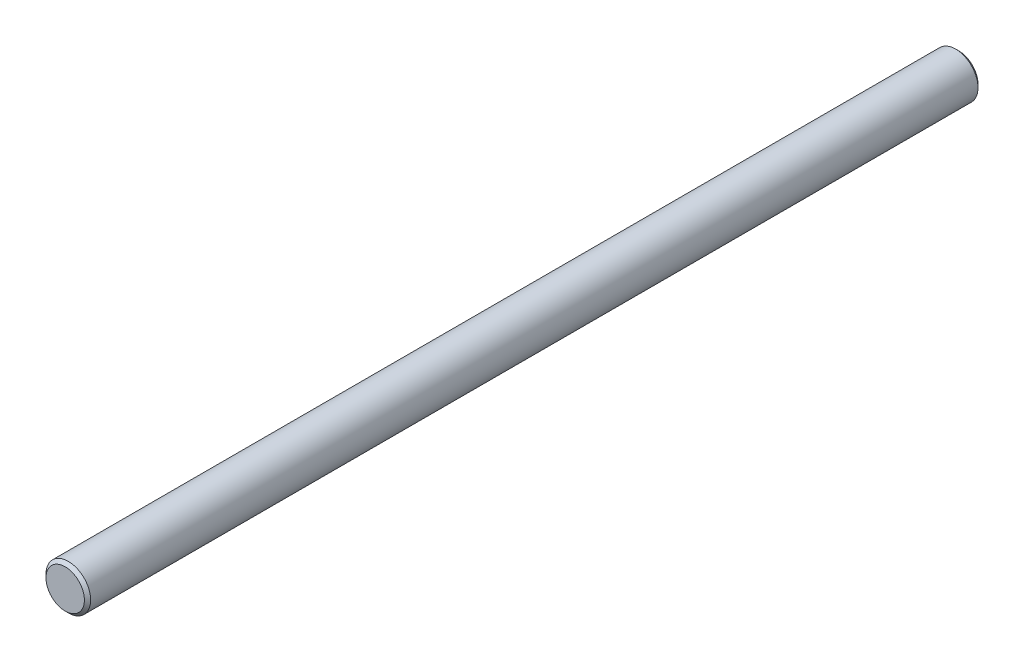
from build123d import *

# Parameters (mm, degrees)
SKETCH3_R                = 15
BOSS_EXTRUDE1_DEPTH      = 300
BOSS_EXTRUDE1_DEPTH_BACK = 300
CHAMFER1_SIZE            = 2.1


with BuildPart() as part:
    # Sketch3 → Boss-Extrude1 (new body, two sides)
    with BuildSketch(Plane.XY) as boss_extrude1_sk:
        Circle(SKETCH3_R)
    extrude(amount=BOSS_EXTRUDE1_DEPTH)
    extrude(boss_extrude1_sk.sketch, amount=-BOSS_EXTRUDE1_DEPTH_BACK)

    # Chamfer1
    chamfer1_edges = [part.edges().sort_by_distance(p)[0] for p in [
        (-15, 0, -300),
        (-15, 0, 300),
    ]]
    chamfer(chamfer1_edges, length=CHAMFER1_SIZE)


solid = part.part
